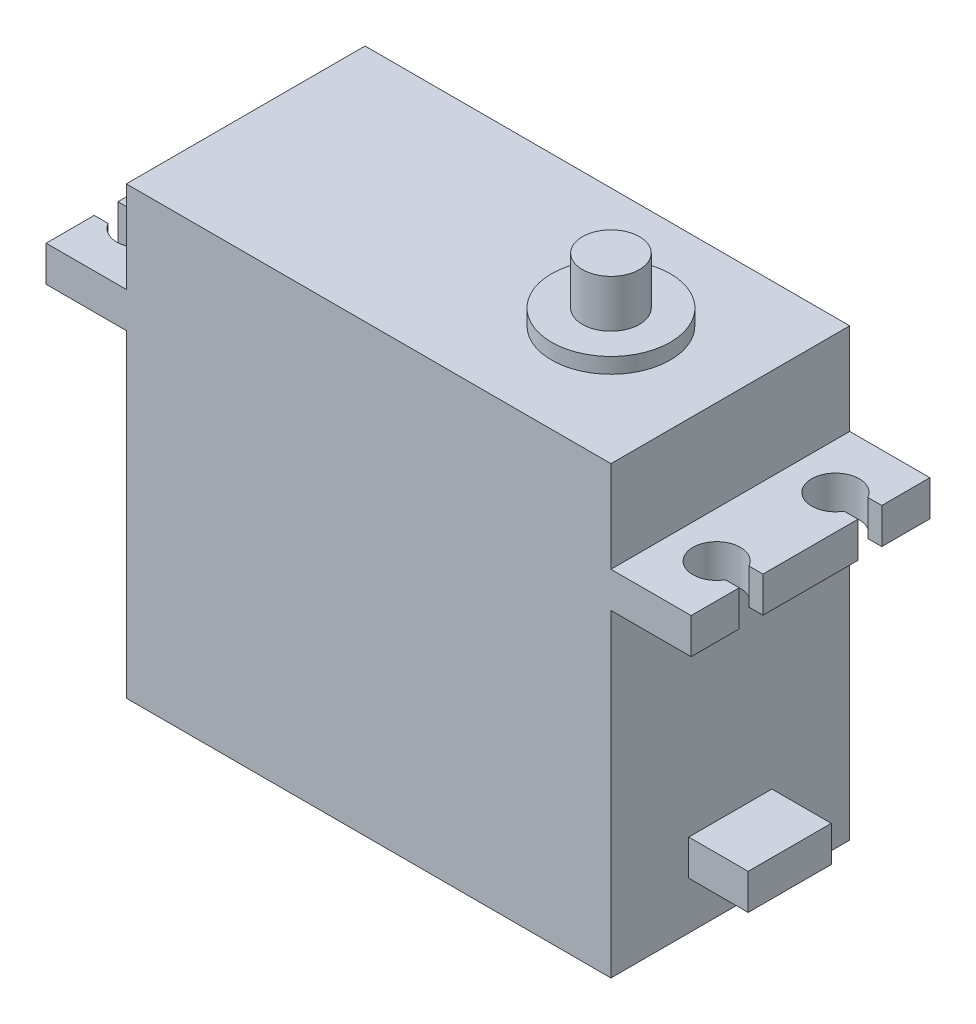
from build123d import *

# Parameters (mm, degrees)
BOSS_EXTRUDE1_START = -10.05
BOSS_EXTRUDE1_DEPTH = 20.1
CUT_EXTRUDE1_DEPTH  = 30.8
SKETCH5_R           = 5
BOSS_EXTRUDE2_DEPTH = 1.3
SKETCH6_R           = 2.4
BOSS_EXTRUDE3_DEPTH = 4
SKETCH8_W           = 7
SKETCH8_H           = 3
BOSS_EXTRUDE4_DEPTH = 5


with BuildPart() as part:
    # Sketch3 → Boss-Extrude1 (new body)
    with BuildSketch(Plane.XY.offset(BOSS_EXTRUDE1_START)):
        Polygon((-30.75, 0), (-30.75, 26.8), (-37.5, 26.8), (-37.5, 29.8), (-30.75, 29.8), (-30.75, 37.5), (10.05, 37.5), (10.05, 29.8), (16.8, 29.8), (16.8, 26.8), (10.05, 26.8), (10.05, 0), align=None)
    extrude(amount=BOSS_EXTRUDE1_DEPTH)

    # Sketch4 → Cut-Extrude1 (cut, through all)
    with BuildSketch(Plane(origin=(0, 29.8, 0), x_dir=(1, 0, 0), z_dir=(0, 1, 0))):
        with BuildLine():
            Line((-37.5, 6), (-37.5, 4))
            Line((-37.5, 4), (-36.332050808, 4))
            ThreePointArc((-36.332050808, 4), (-32.6, 5), (-36.332050808, 6))
            Line((-36.332050808, 6), (-37.5, 6))
        make_face()
        with BuildLine():
            Line((16.8, -6), (15.632050808, -6))
            ThreePointArc((15.632050808, -6), (11.9, -5), (15.632050808, -4))
            Line((15.632050808, -4), (16.8, -4))
            Line((16.8, -4), (16.8, -6))
        make_face()
        with BuildLine():
            Line((-37.5, -4), (-37.5, -6))
            Line((-37.5, -6), (-36.332050808, -6))
            ThreePointArc((-36.332050808, -6), (-32.6, -5), (-36.332050808, -4))
            Line((-36.332050808, -4), (-37.5, -4))
        make_face()
        with BuildLine():
            Line((16.8, 4), (15.632050808, 4))
            ThreePointArc((15.632050808, 4), (11.9, 5), (15.632050808, 6))
            Line((15.632050808, 6), (16.8, 6))
            Line((16.8, 6), (16.8, 4))
        make_face()
    extrude(amount=-CUT_EXTRUDE1_DEPTH, mode=Mode.SUBTRACT)

    # Sketch5 → Boss-Extrude2 (add)
    with BuildSketch(Plane(origin=(0, 37.5, 0), x_dir=(1, 0, 0), z_dir=(0, 1, 0))):
        Circle(SKETCH5_R)
    extrude(amount=BOSS_EXTRUDE2_DEPTH)

    # Sketch6 → Boss-Extrude3 (add)
    with BuildSketch(Plane(origin=(0, 38.8, 0), x_dir=(1, 0, 0), z_dir=(0, 1, 0))):
        Circle(SKETCH6_R)
    extrude(amount=BOSS_EXTRUDE3_DEPTH)

    # Sketch8 → Boss-Extrude4 (add)
    with BuildSketch(Plane(origin=(10.05, 0, 0), x_dir=(0, 0, -1), z_dir=(1, 0, 0))):
        with Locations((0, 5.5)):
            Rectangle(SKETCH8_W, SKETCH8_H)
    extrude(amount=BOSS_EXTRUDE4_DEPTH)


solid = part.part
